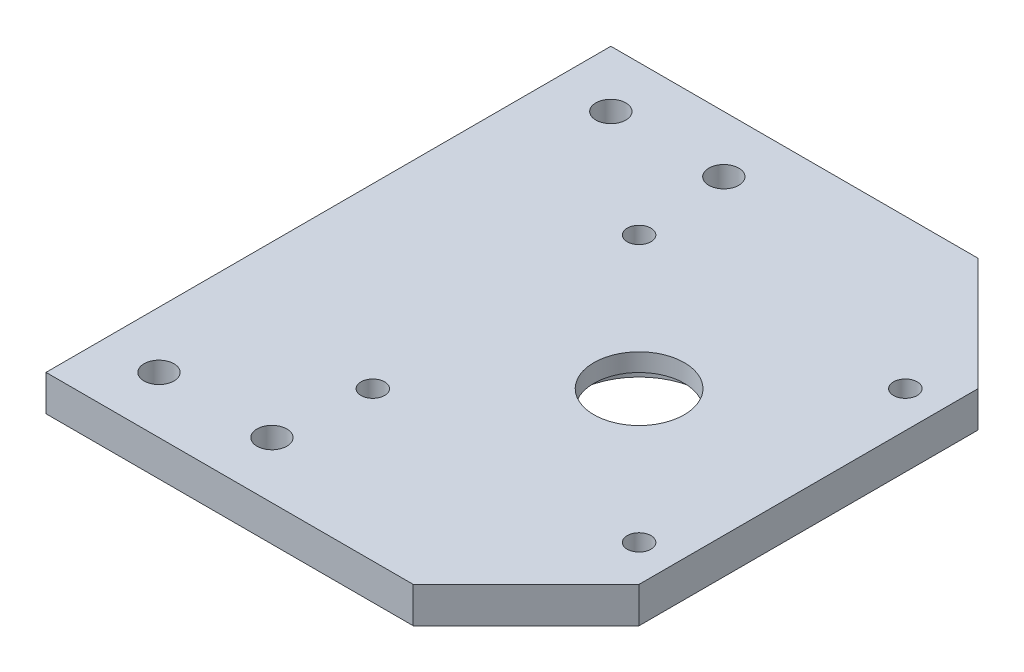
from build123d import *

# Parameters (mm, degrees)
BOSS_EXTRUDE1_DEPTH   = 6.35
M5X0_8_TAPPED_HOLE1_D = 4.2
M5_CLEARANCE_HOLE1_D  = 5.3
SKETCH6_R             = 11.5
CUT_EXTRUDE1_DEPTH    = 3.175
SKETCH7_R             = 8
CUT_EXTRUDE2_DEPTH    = 10


with BuildPart() as part:
    # Sketch1 → Boss-Extrude1 (new body)
    with BuildSketch(Plane(origin=(0, 0, 0), x_dir=(1, 0, 0), z_dir=(0, 1, 0))):
        Polygon((0, 0), (65, 0), (85, -20), (85, -80), (65, -100), (0, -100), align=None)
    extrude(amount=BOSS_EXTRUDE1_DEPTH)

    # M5x0.8 Tapped Hole1 (through all)
    with Locations(Plane(origin=(0, 6.35, 0), x_dir=(1, 0, 0), z_dir=(0, 1, 0))):
        with Locations((78.57, -26.43), (31.43, -26.43), (31.43, -73.57), (78.57, -73.57)):
            Hole(M5X0_8_TAPPED_HOLE1_D / 2)

    # M5 Clearance Hole1 (through all)
    with Locations(Plane(origin=(0, 6.35, 0), x_dir=(1, 0, 0), z_dir=(0, 1, 0))):
        with Locations((10, -10), (30, -10), (10, -90), (30, -90)):
            Hole(M5_CLEARANCE_HOLE1_D / 2)

    # Sketch6 → Cut-Extrude1 (cut)
    with BuildSketch(Plane(origin=(0, 0, 0), x_dir=(1, 0, 0), z_dir=(0, 1, 0))):
        with Locations((55, -50)):
            Circle(SKETCH6_R)
    extrude(amount=CUT_EXTRUDE1_DEPTH, mode=Mode.SUBTRACT)

    # Sketch7 → Cut-Extrude2 (cut)
    with BuildSketch(Plane(origin=(0, 3.175, 0), x_dir=(-1, 0, 0), z_dir=(0, -1, 0))):
        with Locations((-55, -50)):
            Circle(SKETCH7_R)
    extrude(amount=-CUT_EXTRUDE2_DEPTH, mode=Mode.SUBTRACT)


solid = part.part
